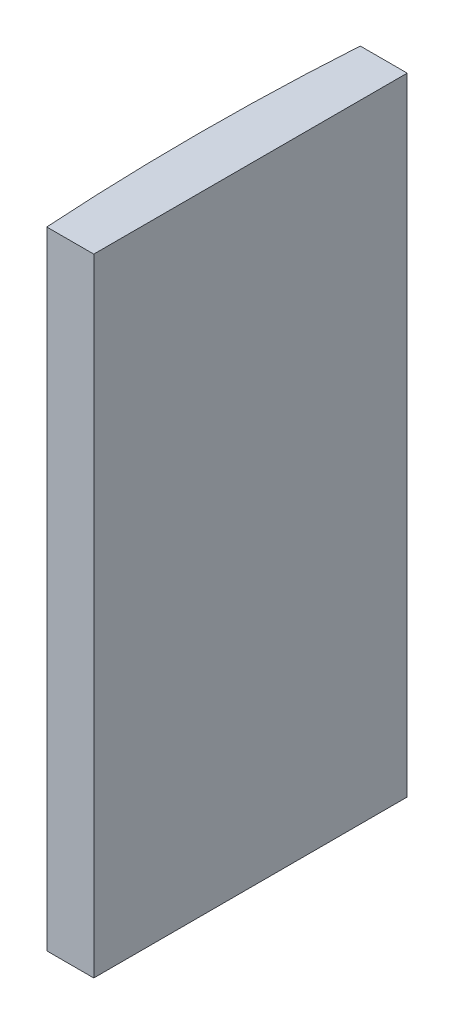
from build123d import *

# Parameters (mm, degrees)
EXTRUDE_1_DEPTH = 40


with BuildPart() as part:
    # 草图1 → 凸台-拉伸1 (new body)
    with BuildSketch(Plane(origin=(0, 0, 0), x_dir=(1, 0, 0), z_dir=(0, 1, 0))):
        with BuildLine():
            Line((-150.422087281, 10), (-147.424795665, 10))
            Line((-147.424795665, 10), (-147.424795665, -10))
            Line((-147.424795665, -10), (-150.422087281, -10))
            ThreePointArc((-150.422087281, -10), (-150.744795665, 0), (-150.422087281, 10))
        make_face()
    extrude(amount=EXTRUDE_1_DEPTH)


solid = part.part
